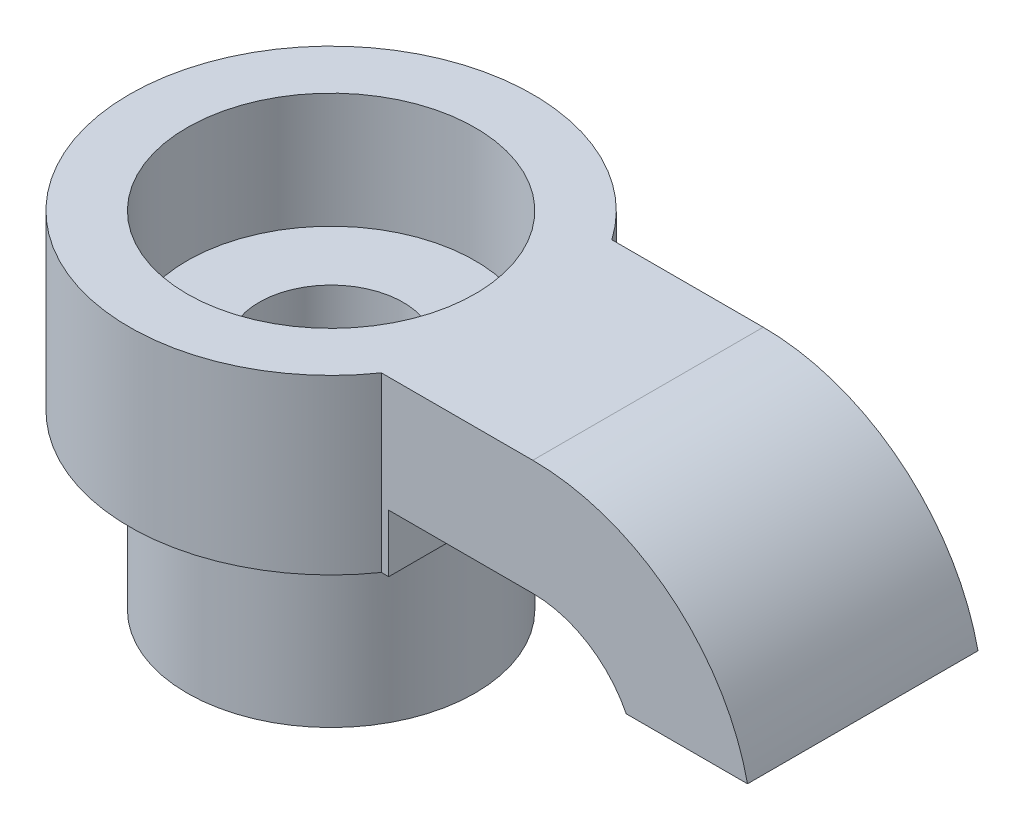
from build123d import *

# Parameters (mm, degrees)
EXTRUDE_1_DEPTH           = 8
EXTRUDE_2_DEPTH           = 6
SKETCH_5_R                = 5
EXTRUDE_3_DEPTH           = 6
HOLE_WIZARD_1_D           = 5
HOLE_WIZARD_1_DEPTH       = 30
HOLE_WIZARD_1_CBORE_D     = 10
HOLE_WIZARD_1_CBORE_DEPTH = 4


with BuildPart() as part:
    # 草图3 → 凸台-拉伸1 (new body)
    with BuildSketch(Plane.XY):
        with BuildLine():
            Line((0, 0), (5, 0))
            ThreePointArc((5, 0), (9.784396345, -1.68635165), (12.453978369, -6))
            Line((12.453978369, -6), (8.243547108, -6))
            ThreePointArc((8.243547108, -6), (6.905295111, -4.540192237), (5, -4))
            Line((5, -4), (0, -4))
            Line((0, -4), (0, 0))
        make_face()
    extrude(amount=EXTRUDE_1_DEPTH)

    # 草图4 → 凸台-拉伸2 (add)
    with BuildSketch(Plane(origin=(0, 0, 0), x_dir=(1, 0, 0), z_dir=(0, 1, 0))):
        with BuildLine():
            Line((-0.255437353, 0), (0, 0))
            Line((0, 0), (0, -8))
            Line((0, -8), (-0.255437353, -8))
            ThreePointArc((-0.255437353, -8), (-13, -4), (-0.255437353, 0))
        make_face()
    extrude(amount=-EXTRUDE_2_DEPTH)

    # 草图5 → 凸台-拉伸3 (add)
    with BuildSketch(Plane.XZ.offset(6)):
        with Locations((-6, 4)):
            Circle(SKETCH_5_R)
    extrude(amount=EXTRUDE_3_DEPTH)

    # 孔1
    with Locations(Plane(origin=(-6, 0, 4), x_dir=(0, 0, 1), z_dir=(0, 1, 0))):
        with Locations((0, 0)):
            CounterBoreHole(HOLE_WIZARD_1_D / 2, HOLE_WIZARD_1_CBORE_D / 2, HOLE_WIZARD_1_CBORE_DEPTH, depth=HOLE_WIZARD_1_DEPTH)


solid = part.part
